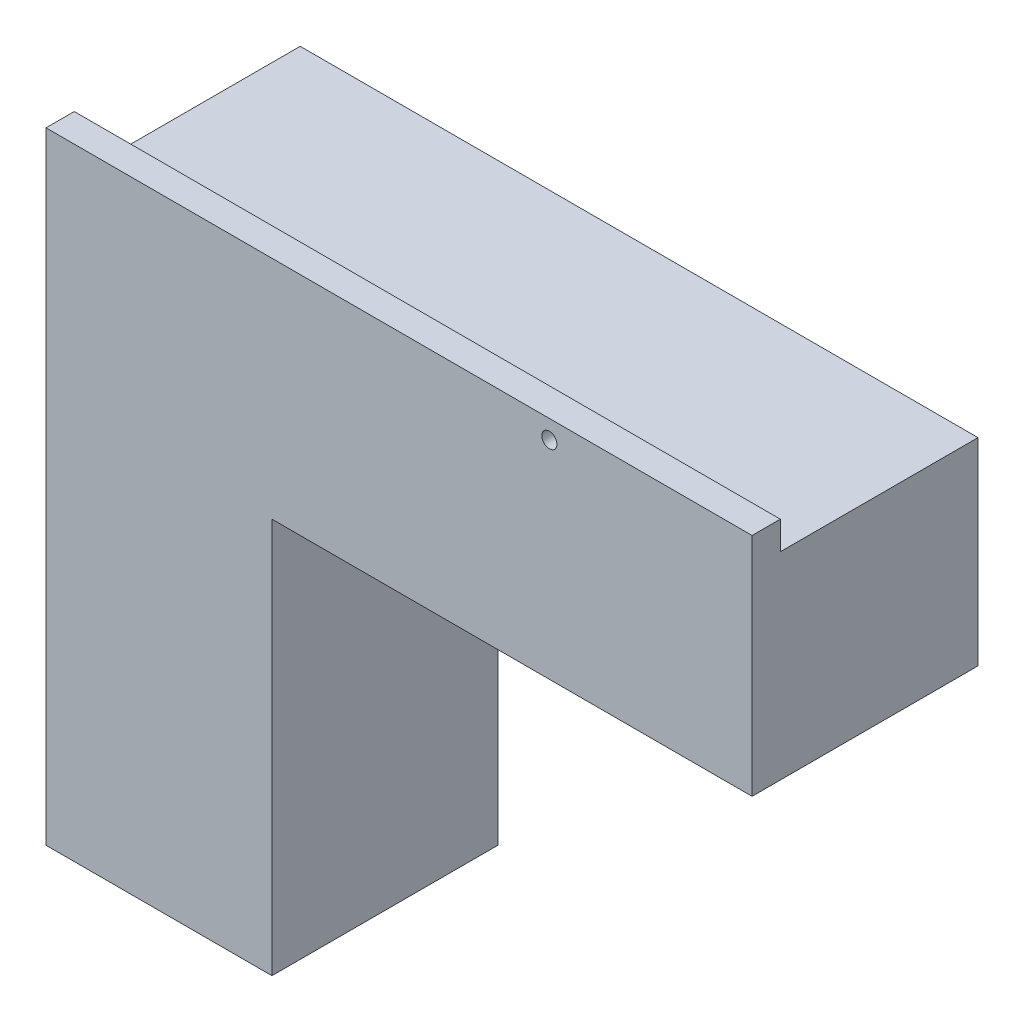
from build123d import *

# Parameters (mm, degrees)
EXTRUDE_1_DEPTH     = 80
SKETCH_2_W          = 10
SKETCH_2_H          = 70
CUT_EXTRUDE_1_DEPTH = 250
SKETCH_3_W          = 70
SKETCH_3_H          = 10
CUT_EXTRUDE_2_DEPTH = 250
SKETCH_4_R          = 2.692710991
CUT_EXTRUDE_3_DEPTH = 10


with BuildPart() as part:
    # Эскиз1 → Бобышка-Вытянуть1 (new body)
    with BuildSketch(Plane.XY):
        Polygon((0, 0), (0, 220), (250, 220), (250, 140), (80, 140), (80, 0), align=None)
    extrude(amount=EXTRUDE_1_DEPTH)

    # Эскиз2 → Вырез-Вытянуть1 (cut)
    with BuildSketch(Plane.XZ):
        with Locations((5, 35)):
            Rectangle(SKETCH_2_W, SKETCH_2_H)
    extrude(amount=-CUT_EXTRUDE_1_DEPTH, mode=Mode.SUBTRACT)

    # Эскиз3 → Вырез-Вытянуть2 (cut)
    with BuildSketch(Plane(origin=(250, 0, 0), x_dir=(0, 0, -1), z_dir=(1, 0, 0))):
        with Locations((-35, 215)):
            Rectangle(SKETCH_3_W, SKETCH_3_H)
    extrude(amount=-CUT_EXTRUDE_2_DEPTH, mode=Mode.SUBTRACT)

    # Эскиз4 → Вырез-Вытянуть3 (cut)
    with BuildSketch(Plane.XY.offset(80)):
        with Locations((178.22144368, 213.38359115)):
            Circle(SKETCH_4_R)
    extrude(amount=-CUT_EXTRUDE_3_DEPTH, mode=Mode.SUBTRACT)


solid = part.part
